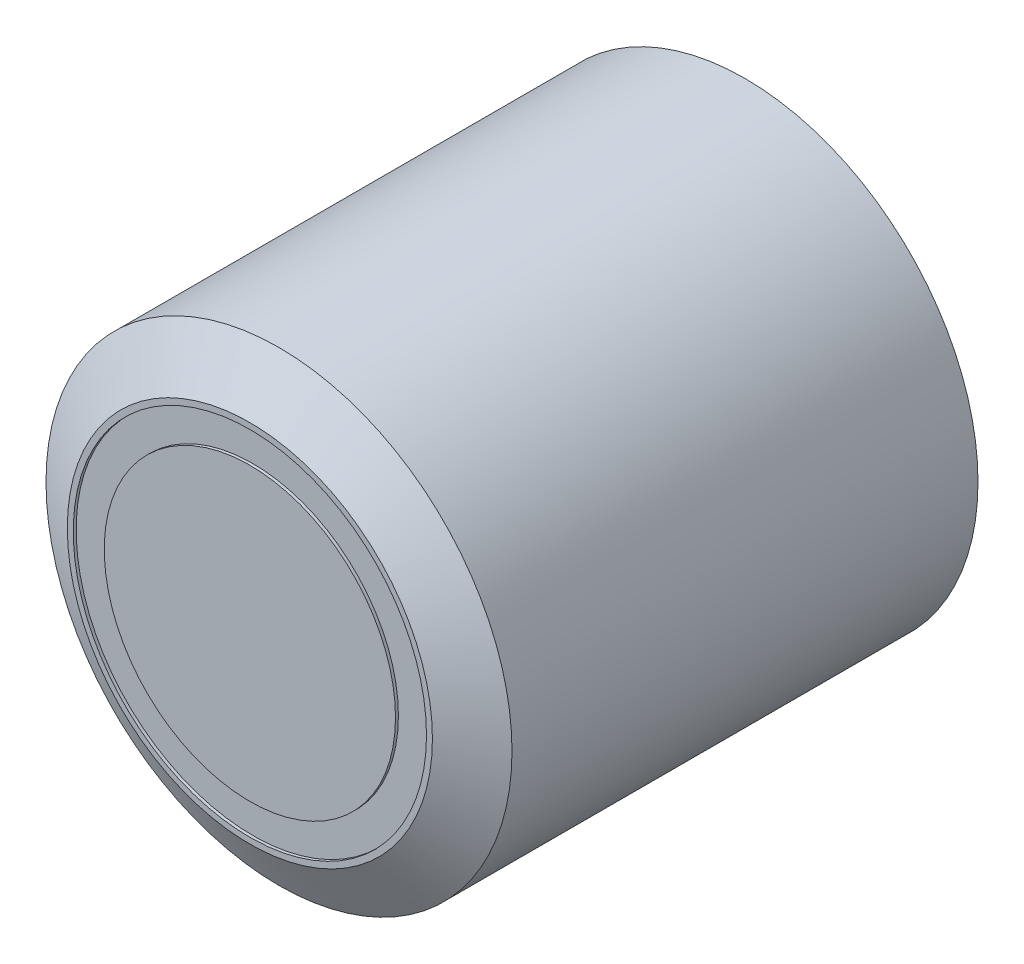
from build123d import *

# Parameters (mm, degrees)
SKETCH2_R           = 8
BOSS_EXTRUDE1_DEPTH = 17
CHAMFER1_SIZE       = 1
CHAMFER1_SIZE2      = 1.732050808
SKETCH5_R           = 6.064278786
CUT_EXTRUDE1_DEPTH  = 0.1
SKETCH6_R           = 5
BOSS_EXTRUDE4_DEPTH = 0.1


with BuildPart() as part:
    # Sketch2 → Boss-Extrude1 (new body)
    with BuildSketch(Plane.XY):
        Circle(SKETCH2_R)
    extrude(amount=BOSS_EXTRUDE1_DEPTH)

    # Chamfer1
    chamfer1_edges = [part.edges().sort_by_distance(p)[0] for p in [
        (-8, 0, 17),
    ]]
    chamfer1_side = [part.faces().sort_by_distance(p)[0] for p in [
        (-8, 0, 8.5),
    ]]
    chamfer(chamfer1_edges, length=CHAMFER1_SIZE, length2=CHAMFER1_SIZE2, reference=chamfer1_side[0])

    # Sketch5 → Cut-Extrude1 (cut)
    with BuildSketch(Plane.XY.offset(17)):
        Circle(SKETCH5_R)
    extrude(amount=-CUT_EXTRUDE1_DEPTH, mode=Mode.SUBTRACT)

    # Sketch6 → Boss-Extrude4 (add)
    with BuildSketch(Plane.XY.offset(16.9)):
        Circle(SKETCH6_R)
    extrude(amount=BOSS_EXTRUDE4_DEPTH)


solid = part.part
